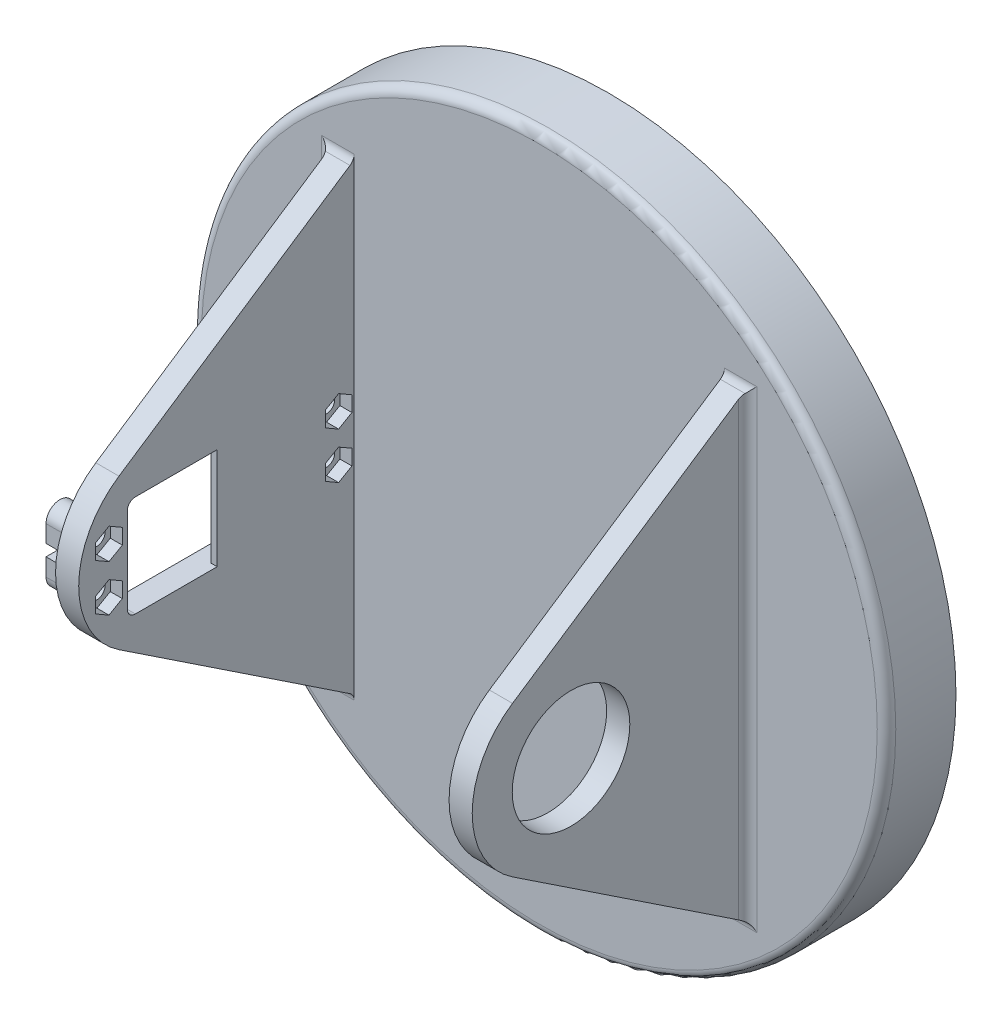
from build123d import *

# Parameters (mm, degrees)
SKETCH1_R           = 75
BASE_PLATE_DEPTH    = 15
SKETCH2_R           = 4.5
DRIVE_HOLES_DEPTH   = 10
CHAMFER1_SIZE       = 1
BASE_START          = 45
BASE_FIN_DEPTH      = 5
BASE_START_2        = 85
BASE_FIN_2_DEPTH    = 5
CUT_EXTRUDE1_REACH  = 122
CUT_EXTRUDE2_REACH  = 122
SKETCH7_R           = 1.75
BOSS_EXTRUDE1_DEPTH = 5.6
SKETCH9_R           = 1.75
CUT_EXTRUDE3_DEPTH  = 5.6
SKETCH10_W          = 4.6
SKETCH10_H          = 2.5
SKETCH10_W_2        = 6
CUT_EXTRUDE4_DEPTH  = 5.6
CUT_EXTRUDE5_DEPTH  = 2.6
BOSS_EXTRUDE2_DEPTH = 1.38
FILLET1_R           = 2
FILLET2_R           = 2
CUT_EXTRUDE6_REACH  = 37
SKETCH13_R          = 12.7
BOSS_EXTRUDE3_DEPTH = 2.5
FILLET3_R           = 2
BOSS_EXTRUDE4_START = 20
BOSS_EXTRUDE4_DEPTH = 2.5
BOSS_EXTRUDE5_START = 20
BOSS_EXTRUDE5_DEPTH = 2.5
FILLET4_R           = 2


with BuildPart() as part:
    # Sketch1 → Base Plate (new body)
    with BuildSketch(Plane.XY):
        Circle(SKETCH1_R)
    extrude(amount=BASE_PLATE_DEPTH)

    # Sketch2 → Drive Holes (cut)
    with BuildSketch(Plane(origin=(0, 0, 0), x_dir=(-1, 0, 0), z_dir=(0, 0, -1))):
        with Locations((0, -25)):
            Circle(SKETCH2_R)
        with Locations((-23.776412907, -7.725424859)):
            Circle(SKETCH2_R)
        with Locations((-14.694631307, 20.225424859)):
            Circle(SKETCH2_R)
        with Locations((14.694631307, 20.225424859)):
            Circle(SKETCH2_R)
        with Locations((23.776412907, -7.725424859)):
            Circle(SKETCH2_R)
    extrude(amount=-DRIVE_HOLES_DEPTH, mode=Mode.SUBTRACT)

    # Chamfer1
    chamfer1_edges = [part.edges().sort_by_distance(p)[0] for p in [
        (28.276412907, -7.725424859, 0),
        (19.194631307, 20.225424859, 0),
        (-10.194631307, 20.225424859, 0),
        (-19.276412907, -7.725424859, 0),
        (4.5, -25, 0),
    ]]
    chamfer(chamfer1_edges, length=CHAMFER1_SIZE)

    # Sketch4 → Base Fin (add)
    with BuildSketch(Plane(origin=(0, 0, 0), x_dir=(0, 0, -1), z_dir=(1, 0, 0)).offset(BASE_START)):
        with BuildLine():
            Line((-15, 50), (-65.791986374, 16.233382914))
            ThreePointArc((-65.791986374, 16.233382914), (-74.493324261, 0), (-65.791986374, -16.233382914))
            Line((-65.791986374, -16.233382914), (-15, -50))
            Line((-15, -50), (-15, 50))
        make_face()
    extrude(amount=-BASE_FIN_DEPTH)

    # Sketch5 → Base Fin 2 (add)
    with BuildSketch(Plane.ZY.offset(-40).offset(BASE_START_2)):
        with BuildLine():
            Line((15, 50), (15, -50))
            Line((15, -50), (65.791986374, -16.233382914))
            ThreePointArc((65.791986374, -16.233382914), (74.493324261, 0), (65.791986374, 16.233382914))
            Line((65.791986374, 16.233382914), (15, 50))
        make_face()
    extrude(amount=-BASE_FIN_2_DEPTH)

    # Sketch6 → Cut-Extrude1 (cut, up to next)
    with BuildSketch(Plane.ZY.offset(45), mode=Mode.PRIVATE) as cut_extrude1_sk1:
        with BuildLine():
            Line((64, 8.832406236), (64, -9.567593764))
            ThreePointArc((64, -9.567593764), (63.487436867, -10.805030631), (62.25, -11.317593764))
            Line((62.25, -11.317593764), (24.05, -11.317593764))
            ThreePointArc((24.05, -11.317593764), (22.812563133, -10.805030631), (22.3, -9.567593764))
            Line((22.3, -9.567593764), (22.3, 8.832406236))
            ThreePointArc((22.3, 8.832406236), (22.812563133, 10.069843103), (24.05, 10.582406236))
            Line((24.05, 10.582406236), (62.25, 10.582406236))
            ThreePointArc((62.25, 10.582406236), (63.487436867, 10.069843103), (64, 8.832406236))
        make_face()
    cut_extrude1_tool1 = extrude(cut_extrude1_sk1.sketch, amount=-CUT_EXTRUDE1_REACH, mode=Mode.PRIVATE) & part.part
    add(cut_extrude1_tool1.solids().sort_by_distance((-45, -0.367594, 43.15))[0], mode=Mode.SUBTRACT)

    # Sketch7 → Cut-Extrude2 (cut, up to next)
    with BuildSketch(Plane.ZY.offset(45), mode=Mode.PRIVATE) as cut_extrude2_sk1:
        with Locations((18.35, 4.632406236)):
            Circle(SKETCH7_R)
    cut_extrude2_tool1 = extrude(cut_extrude2_sk1.sketch, amount=-CUT_EXTRUDE2_REACH, mode=Mode.PRIVATE) & part.part
    add(cut_extrude2_tool1.solids().sort_by_distance((-45, 4.632406, 18.35))[0], mode=Mode.SUBTRACT)
    # Sketch7 → Cut-Extrude2 (cut, up to next)
    with BuildSketch(Plane.ZY.offset(45), mode=Mode.PRIVATE) as cut_extrude2_sk2:
        with Locations((18.35, -5.367593764)):
            Circle(SKETCH7_R)
    cut_extrude2_tool2 = extrude(cut_extrude2_sk2.sketch, amount=-CUT_EXTRUDE2_REACH, mode=Mode.PRIVATE) & part.part
    add(cut_extrude2_tool2.solids().sort_by_distance((-45, -5.367594, 18.35))[0], mode=Mode.SUBTRACT)
    # Sketch7 → Cut-Extrude2 (cut, up to next)
    with BuildSketch(Plane.ZY.offset(45), mode=Mode.PRIVATE) as cut_extrude2_sk3:
        with Locations((67.95, -5.367593764)):
            Circle(SKETCH7_R)
    cut_extrude2_tool3 = extrude(cut_extrude2_sk3.sketch, amount=-CUT_EXTRUDE2_REACH, mode=Mode.PRIVATE) & part.part
    add(cut_extrude2_tool3.solids().sort_by_distance((-45, -5.367594, 67.95))[0], mode=Mode.SUBTRACT)
    # Sketch7 → Cut-Extrude2 (cut, up to next)
    with BuildSketch(Plane.ZY.offset(45), mode=Mode.PRIVATE) as cut_extrude2_sk4:
        with Locations((67.95, 4.632406236)):
            Circle(SKETCH7_R)
    cut_extrude2_tool4 = extrude(cut_extrude2_sk4.sketch, amount=-CUT_EXTRUDE2_REACH, mode=Mode.PRIVATE) & part.part
    add(cut_extrude2_tool4.solids().sort_by_distance((-45, 4.632406, 67.95))[0], mode=Mode.SUBTRACT)

    # Sketch8 → Boss-Extrude1 (add)
    with BuildSketch(Plane.ZY.offset(45)):
        with BuildLine():
            Line((70.95, 4.632406236), (70.95, -5.367593764))
            ThreePointArc((70.95, -5.367593764), (67.95, -8.367593764), (64.95, -5.367593764))
            Line((64.95, -5.367593764), (64.95, 4.632406236))
            ThreePointArc((64.95, 4.632406236), (67.95, 7.632406236), (70.95, 4.632406236))
        make_face()
        with BuildLine():
            Line((15, 7.632406236), (15, 0))
            Line((15, 0), (15, -8.367593764))
            Line((15, -8.367593764), (18.35, -8.367593764))
            ThreePointArc((18.35, -8.367593764), (20.471320344, -7.488914107), (21.35, -5.367593764))
            Line((21.35, -5.367593764), (21.35, 4.632406236))
            ThreePointArc((21.35, 4.632406236), (20.471320344, 6.75372658), (18.35, 7.632406236))
            Line((18.35, 7.632406236), (15, 7.632406236))
        make_face()
    extrude(amount=BOSS_EXTRUDE1_DEPTH)

    # Sketch9 → Cut-Extrude3 (cut)
    with BuildSketch(Plane(origin=(-45, 0, 0), x_dir=(0, 0, -1), z_dir=(1, 0, 0))):
        with Locations((-67.95, -5.367593764)):
            Circle(SKETCH9_R)
        with Locations((-67.95, 4.632406236)):
            Circle(SKETCH9_R)
        with Locations((-18.35, -5.367593764)):
            Circle(SKETCH9_R)
        with Locations((-18.35, 4.632406236)):
            Circle(SKETCH9_R)
    extrude(amount=-CUT_EXTRUDE3_DEPTH, mode=Mode.SUBTRACT)

    # Sketch10 → Cut-Extrude4 (cut)
    with BuildSketch(Plane.ZY.offset(50.6)):
        with Locations((19.05, -0.367593764)):
            Rectangle(SKETCH10_W, SKETCH10_H)
        with Locations((67.95, -0.324654002)):
            Rectangle(SKETCH10_W_2, SKETCH10_H)
    extrude(amount=-CUT_EXTRUDE4_DEPTH, mode=Mode.SUBTRACT)

    # Sketch11 → Cut-Extrude5 (cut)
    with BuildSketch(Plane(origin=(-40, 0, 0), x_dir=(0, 0, -1), z_dir=(1, 0, 0))):
        Polygon((-65.075, -7.027475787), (-65.075, -3.70771174), (-67.95, -2.047829716), (-70.825, -3.70771174), (-70.825, -7.027475787), (-67.95, -8.687357811), align=None)
        Polygon((-65.075, 2.972524213), (-65.075, 6.29228826), (-67.95, 7.952170284), (-70.825, 6.29228826), (-70.825, 2.972524213), (-67.95, 1.312642189), align=None)
        Polygon((-15.475, -7.027475787), (-15.475, -3.70771174), (-18.35, -2.047829716), (-21.225, -3.70771174), (-21.225, -7.027475787), (-18.35, -8.687357811), align=None)
        Polygon((-15.475, 2.972524213), (-15.475, 6.29228826), (-18.35, 7.952170284), (-21.225, 6.29228826), (-21.225, 2.972524213), (-18.35, 1.312642189), align=None)
    extrude(amount=-CUT_EXTRUDE5_DEPTH, mode=Mode.SUBTRACT)

    # Sketch12 → Boss-Extrude2 (add)
    with BuildSketch(Plane(origin=(-40, 0, 0), x_dir=(0, 0, -1), z_dir=(1, 0, 0))):
        with BuildLine():
            Line((-44.572101834, -11.317593764), (-44.572101834, 10.582406236))
            Line((-44.572101834, 10.582406236), (-24.05, 10.582406236))
            ThreePointArc((-24.05, 10.582406236), (-22.812563133, 10.069843103), (-22.3, 8.832406236))
            Line((-22.3, 8.832406236), (-22.3, -9.567593764))
            ThreePointArc((-22.3, -9.567593764), (-22.812563133, -10.805030631), (-24.05, -11.317593764))
            Line((-24.05, -11.317593764), (-44.572101834, -11.317593764))
        make_face()
    extrude(amount=-BOSS_EXTRUDE2_DEPTH)

    # Fillet1
    fillet1_edges = [part.edges().sort_by_distance(p)[0] for p in [
        (-45, -29.183796882, 15),
        (-47.8, -8.367593764, 15),
        (-47.8, 7.632406236, 15),
        (42.5, 50, 15),
        (42.5, -50, 15),
        (45, 0, 15),
        (-42.5, 50, 15),
        (-42.5, -50, 15),
        (-45, 28.816203118, 15),
    ]]
    fillet(fillet1_edges, radius=FILLET1_R)

    # Fillet2
    fillet2_edges = [part.edges().sort_by_distance(p)[0] for p in [
        (-75, 0, 15),
    ]]
    fillet(fillet2_edges, radius=FILLET2_R)

    # Sketch13 → Cut-Extrude6 (cut, up to next)
    with BuildSketch(Plane.ZY.offset(-40), mode=Mode.PRIVATE) as cut_extrude6_sk1:
        with Locations((53.15, -0.367593764)):
            Circle(SKETCH13_R)
    cut_extrude6_tool1 = extrude(cut_extrude6_sk1.sketch, amount=-CUT_EXTRUDE6_REACH, mode=Mode.PRIVATE) & part.part
    add(cut_extrude6_tool1.solids().sort_by_distance((40, -0.367594, 53.15))[0], mode=Mode.SUBTRACT)

    # Sketch15 → Boss-Extrude3 (add, symmetric)
    with BuildSketch(Plane(origin=(0, 0, 0), x_dir=(-1, 0, 0), z_dir=(0, 1, 0))):
        Polygon((42.667233731, 15), (42.667233731, 34.681775652), (62.349009383, 15), align=None)
    extrude(amount=BOSS_EXTRUDE3_DEPTH, both=True)

    # Fillet3
    fillet3_edges = [part.edges().sort_by_distance(p)[0] for p in [
        (-56.474504691, -2.5, 15),
        (-56.474504691, 2.5, 15),
        (-62.349009383, 0, 15),
    ]]
    fillet(fillet3_edges, radius=FILLET3_R)

    # Sketch17 → Boss-Extrude4 (add, symmetric)
    with BuildSketch(Plane(origin=(0, 0, 0), x_dir=(1, 0, 0), z_dir=(0, 1, 0)).offset(BOSS_EXTRUDE4_START)):
        Polygon((-42.667233731, -13), (-42.667233731, -30.724225819), (-60.39145955, -13), align=None)
    extrude(amount=BOSS_EXTRUDE4_DEPTH, both=True)

    # Sketch18 → Boss-Extrude5 (add, symmetric)
    with BuildSketch(Plane(origin=(0, 0, 0), x_dir=(-1, 0, 0), z_dir=(0, 1, 0)).offset(BOSS_EXTRUDE5_START)):
        Polygon((58.39145955, 15), (45, 28.39145955), (45, 15), align=None)
    extrude(amount=BOSS_EXTRUDE5_DEPTH, both=True)

    # Fillet4
    fillet4_edges = [part.edges().sort_by_distance(p)[0] for p in [
        (-45.585786438, 17.5, 15.585786438),
        (-45.585786438, 22.5, 15.585786438),
        (-45, 20, 28.39145955),
        (-58.39145955, 20, 15),
        (-52.695729775, 22.5, 15),
        (-45, 22.5, 22.695729775),
        (-52.695729775, 17.5, 15),
        (-45, 17.5, 22.695729775),
    ]]
    fillet(fillet4_edges, radius=FILLET4_R)


solid = part.part
